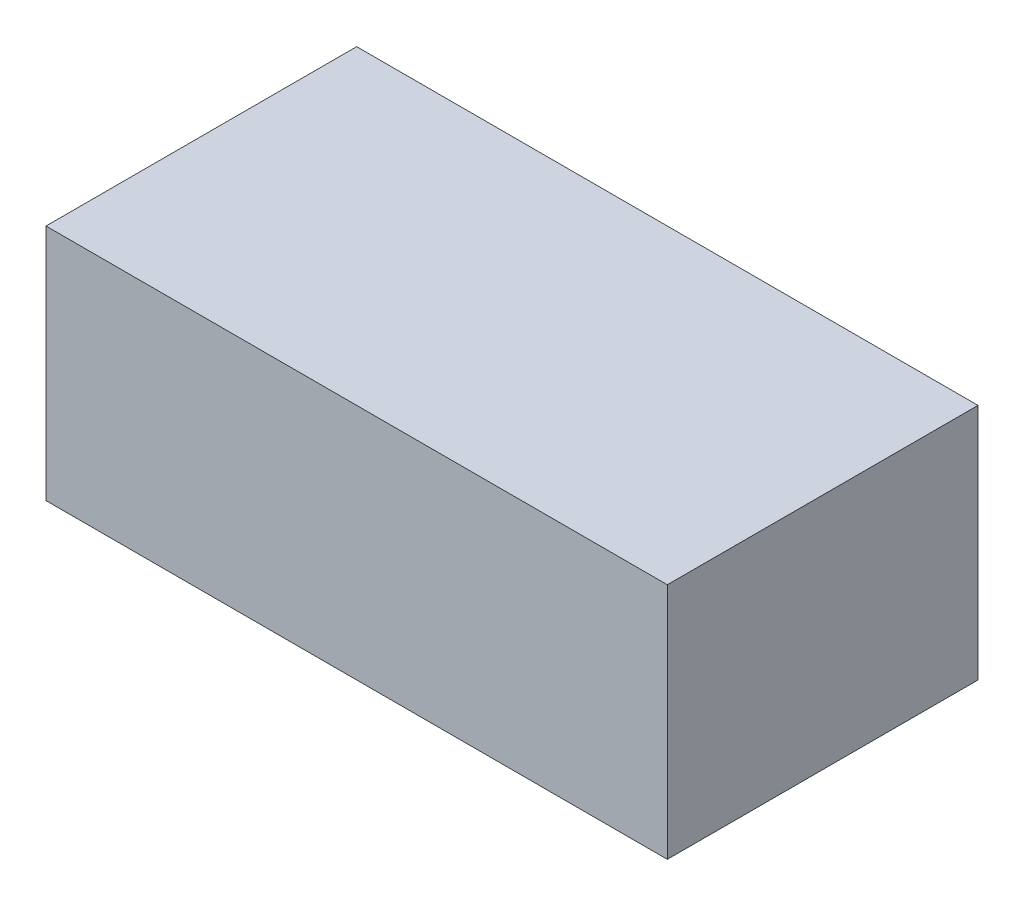
from build123d import *

# Parameters (mm, degrees)
SKETCH4_W           = 290
SKETCH4_H           = 145
BOSS_EXTRUDE3_DEPTH = 111
SKETCH5_W           = 286
SKETCH5_H           = 141
CUT_EXTRUDE2_DEPTH  = 110.8


with BuildPart() as part:
    # Sketch4 → Boss-Extrude3 (new body)
    with BuildSketch(Plane(origin=(0, 0, 0), x_dir=(1, 0, 0), z_dir=(0, 1, 0))):
        Rectangle(SKETCH4_W, SKETCH4_H)
    extrude(amount=BOSS_EXTRUDE3_DEPTH)

    # Sketch5 → Cut-Extrude2 (cut)
    with BuildSketch(Plane(origin=(0, 0, 0), x_dir=(1, 0, 0), z_dir=(0, 1, 0))):
        Rectangle(SKETCH5_W, SKETCH5_H)
    extrude(amount=CUT_EXTRUDE2_DEPTH, mode=Mode.SUBTRACT)


solid = part.part
